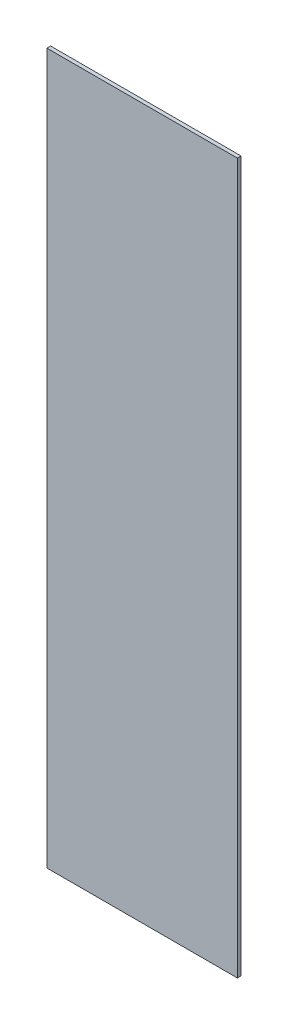
from build123d import *

# Parameters (mm, degrees)
SKETCH1_W           = 327.025
SKETCH1_H           = 1219.2
BOSS_EXTRUDE1_DEPTH = 6.35


with BuildPart() as part:
    # Sketch1 → Boss-Extrude1 (new body)
    with BuildSketch(Plane.XY):
        with Locations((542.093594865, -1199.640687798)):
            Rectangle(SKETCH1_W, SKETCH1_H)
    extrude(amount=BOSS_EXTRUDE1_DEPTH)


solid = part.part
